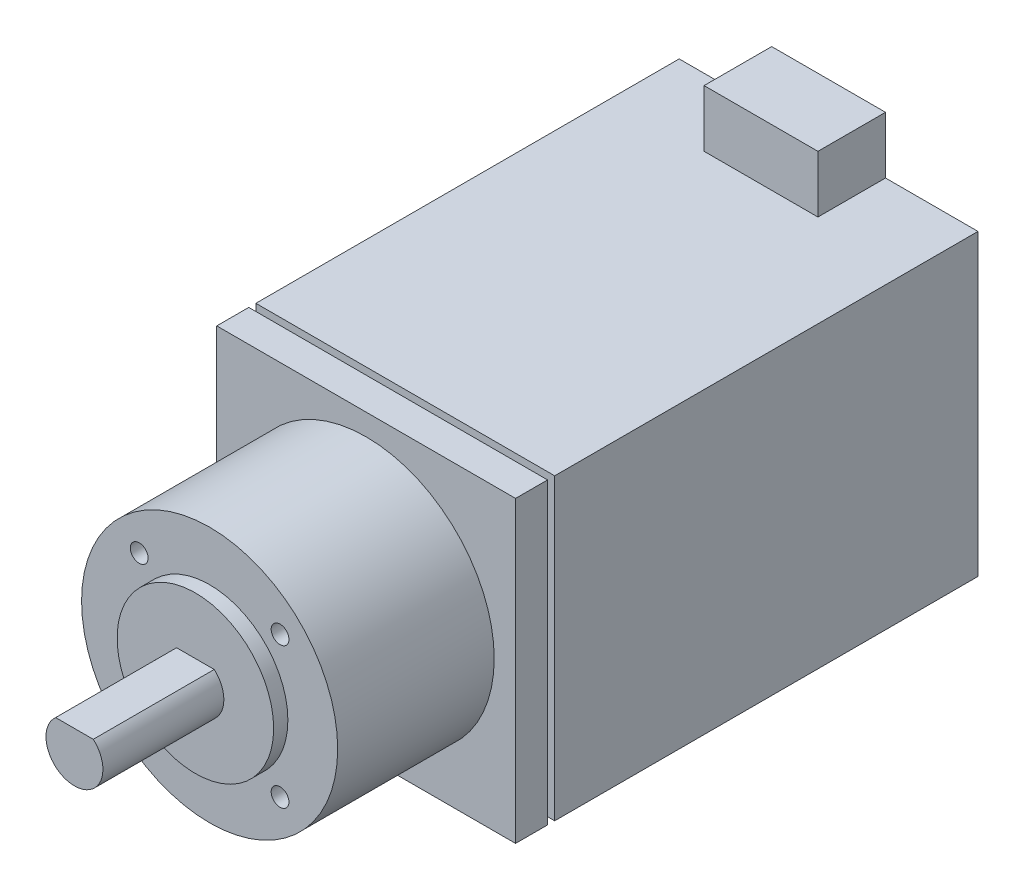
from build123d import *

# Parameters (mm, degrees)
SKETCH_1_W               = 42
SKETCH_1_H               = 42
EXTRUDE_1_DEPTH          = 65
SKETCH_2_R               = 18
EXTRUDE_2_DEPTH          = 22
EXTRUDE_3_DEPTH          = 19
SKETCH_4_R               = 11
EXTRUDE_4_DEPTH          = 2
SKETCH_6_W               = 43
SKETCH_6_H               = 1
CUT_EXTRUDE_1_DEPTH      = 2
PATTERN_CIRCULAR_1_COUNT = 4
HOLE_WIZARD_M3_1_D       = 2.5
HOLE_WIZARD_M3_1_DEPTH   = 7.5
HOLE_WIZARD_M3_1_TIP     = 0.751075774
SKETCH_9_W               = 16
SKETCH_9_H               = 9.5
EXTRUDE_5_DEPTH          = 8


with BuildPart() as part:
    # 草图1 → 凸台-拉伸1 (new body)
    with BuildSketch(Plane.XY):
        Rectangle(SKETCH_1_W, SKETCH_1_H)
    extrude(amount=EXTRUDE_1_DEPTH)

    # 草图2 → 凸台-拉伸2 (add)
    with BuildSketch(Plane.XY.offset(65)):
        Circle(SKETCH_2_R)
    extrude(amount=EXTRUDE_2_DEPTH)

    # 草图3 → 凸台-拉伸3 (add)
    with BuildSketch(Plane.XY.offset(87)):
        with BuildLine():
            Line((-2.645751311, 3), (2.645751311, 3))
            ThreePointArc((2.645751311, 3), (0, -4), (-2.645751311, 3))
        make_face()
    extrude(amount=EXTRUDE_3_DEPTH)

    # 草图4 → 凸台-拉伸4 (add)
    with BuildSketch(Plane.XY.offset(87)):
        Circle(SKETCH_4_R)
    extrude(amount=EXTRUDE_4_DEPTH)

    # 草图6 → 切除-拉伸1 (cut)
    with BuildSketch(Plane(origin=(0, 21, 0), x_dir=(1, 0, 0), z_dir=(0, 1, 0))):
        with Locations((0, -60)):
            Rectangle(SKETCH_6_W, SKETCH_6_H)
    cut_extrude_1 = extrude(amount=-CUT_EXTRUDE_1_DEPTH, mode=Mode.SUBTRACT)

    # 阵列(圆周)1: 切除-拉伸1 ×4 about axis
    pattern_circular_1_axis = Axis((0, 0, 0), (0, 0, 1))
    for i in range(1, PATTERN_CIRCULAR_1_COUNT):
        add(cut_extrude_1.rotate(pattern_circular_1_axis, i * 360 / PATTERN_CIRCULAR_1_COUNT), mode=Mode.SUBTRACT)

    # M3 螺纹孔1
    with Locations(Plane(origin=(-9.899494937, 9.899494937, 87), x_dir=(1, 0, 0), z_dir=(0, 0, 1))):
        with Locations((0, 0), (0, -19.798989874), (19.798989874, 0), (19.798989874, -19.798989874)):
            Hole(HOLE_WIZARD_M3_1_D / 2, depth=HOLE_WIZARD_M3_1_DEPTH)
            with Locations((0, 0, -(HOLE_WIZARD_M3_1_DEPTH + HOLE_WIZARD_M3_1_TIP / 2))):  # 118° drill point
                Cone(0, HOLE_WIZARD_M3_1_D / 2, HOLE_WIZARD_M3_1_TIP, mode=Mode.SUBTRACT)

    # 草图9 → 凸台-拉伸5 (add)
    with BuildSketch(Plane(origin=(0, 21, 0), x_dir=(1, 0, 0), z_dir=(0, 1, 0))):
        with Locations((0, -4.75)):
            Rectangle(SKETCH_9_W, SKETCH_9_H)
    extrude(amount=EXTRUDE_5_DEPTH)


solid = part.part
